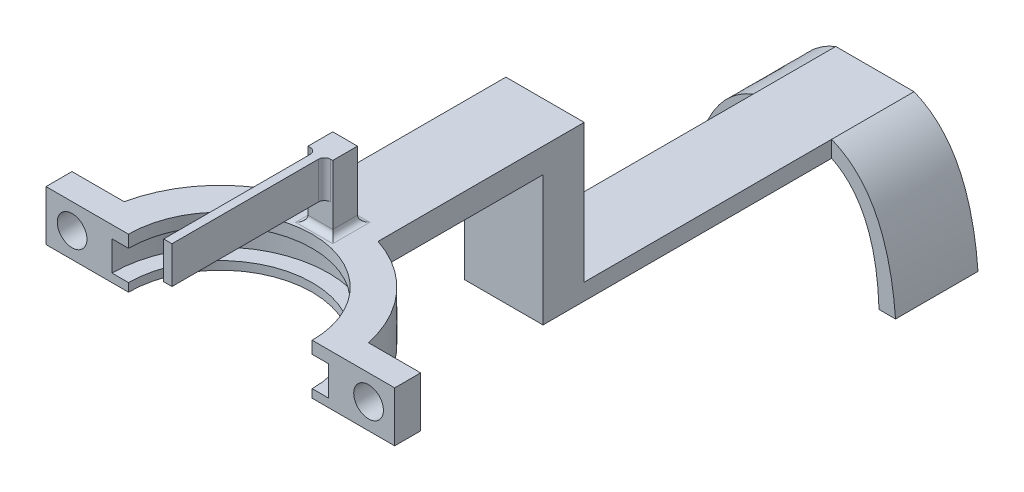
from build123d import *

# Parameters (mm, degrees)
BOSS_EXTRUDE1_DEPTH = 6.5
BOSS_EXTRUDE2_DEPTH = 3
BOSS_EXTRUDE3_DEPTH = 3
SKETCH10_W          = 9.5
SKETCH10_H          = 5
BOSS_EXTRUDE4_DEPTH = 15.78
SKETCH11_W          = 9.5
SKETCH11_H          = 2
BOSS_EXTRUDE5_DEPTH = 40
BOSS_EXTRUDE6_DEPTH = 6.09393
SKETCH14_R          = 1.8
CUT_EXTRUDE1_DEPTH  = 6.3
SKETCH15_W          = 51.153217575
SKETCH15_H          = 21.210560201
CUT_EXTRUDE3_DEPTH  = 19.78
SKETCH18_W          = 3
SKETCH18_H          = 3
BOSS_EXTRUDE7_DEPTH = 6.5
FILLET1_R           = 0.75
BOSS_EXTRUDE8_DEPTH = 1.5
FILLET2_R           = 0.75
BOSS_EXTRUDE9_DEPTH = 10


with BuildPart() as part:
    # Sketch3 → Revolve1 (revolve)
    with BuildSketch(Plane.XY):
        Polygon((-62.694264441, 11.733728816), (-64.884531744, 11.733728816), (-64.884531744, 5.639799249), (-60.884531744, 5.639799249), (-60.884531744, 6.650679103), (-62.884531744, 6.650679103), (-62.884531744, 10.250679103), (-60.884531744, 10.250679103), (-60.884531744, 11.733728816), align=None)
    revolve(axis=Axis((-49.744264441, 0, 0), (0, 1, 0)))

    # Sketch7 → Boss-Extrude1 (add)
    with BuildSketch(Plane(origin=(0, 11.733728816, 0), x_dir=(1, 0, 0), z_dir=(0, 1, 0))):
        with BuildLine():
            Line((-50.244264441, 15.132008921), (-50.244264441, 13.130751112))
            ThreePointArc((-50.244264441, 13.130751112), (-49.744264441, 13.140267302), (-49.244264441, 13.130751112))
            Line((-49.244264441, 13.130751112), (-49.244264441, 15.132008921))
            ThreePointArc((-49.244264441, 15.132008921), (-49.744264441, 15.140267302), (-50.244264441, 15.132008921))
        make_face()
    extrude(amount=BOSS_EXTRUDE1_DEPTH)

    # Sketch8 → Boss-Extrude2 (add)
    with BuildSketch(Plane(origin=(0, 18.233728816, 0), x_dir=(1, 0, 0), z_dir=(0, 1, 0))):
        with BuildLine():
            Line((-50.244264441, 15.132008921), (-50.244264441, 13.130751112))
            Line((-50.244264441, 13.130751112), (-50.244264441, -6.369248888))
            Line((-50.244264441, -6.369248888), (-49.244264441, -6.369248888))
            Line((-49.244264441, -6.369248888), (-49.244264441, 13.130751112))
            Line((-49.244264441, 13.130751112), (-49.244264441, 15.132008921))
            ThreePointArc((-49.244264441, 15.132008921), (-49.744264441, 15.140267302), (-50.244264441, 15.132008921))
        make_face()
    extrude(amount=-BOSS_EXTRUDE2_DEPTH)

    # Sketch9 → Boss-Extrude3 (add)
    with BuildSketch(Plane(origin=(0, 11.733728816, 0), x_dir=(1, 0, 0), z_dir=(0, 1, 0))):
        with BuildLine():
            Line((-54.494264441, 14.375854548), (-54.494264441, 39.375854548))
            Line((-54.494264441, 39.375854548), (-44.994264441, 39.375854548))
            Line((-44.994264441, 39.375854548), (-44.994264441, 14.375854548))
            ThreePointArc((-44.994264441, 14.375854548), (-47.092177082, 14.906177465), (-49.244264441, 15.132008921))
            ThreePointArc((-49.244264441, 15.132008921), (-49.744264441, 15.140267302), (-50.244264441, 15.132008921))
            ThreePointArc((-50.244264441, 15.132008921), (-52.3963518, 14.906177465), (-54.494264441, 14.375854548))
        make_face()
    extrude(amount=-BOSS_EXTRUDE3_DEPTH)

    # Sketch10 → Boss-Extrude4 (add)
    with BuildSketch(Plane.XZ.offset(-8.733728816)):
        with Locations((-49.744264441, -36.875854548)):
            Rectangle(SKETCH10_W, SKETCH10_H)
    extrude(amount=BOSS_EXTRUDE4_DEPTH)

    # Sketch11 → Boss-Extrude5 (add)
    with BuildSketch(Plane(origin=(0, 0, -39.375854548), x_dir=(-1, 0, 0), z_dir=(0, 0, -1))):
        with Locations((49.744264441, -6.046271184)):
            Rectangle(SKETCH11_W, SKETCH11_H)
    extrude(amount=BOSS_EXTRUDE5_DEPTH)

    # Sketch13 → Boss-Extrude6 (add)
    with BuildSketch(Plane(origin=(0, 11.733728816, 0), x_dir=(1, 0, 0), z_dir=(0, 1, 0))):
        with BuildLine():
            Line((-28.603997139, 3.15), (-34.935307895, 3.15))
            ThreePointArc((-34.935307895, 3.15), (-34.603997139, 0), (-34.935307895, -3.15))
            Line((-34.935307895, -3.15), (-28.603997139, -3.15))
            Line((-28.603997139, -3.15), (-28.603997139, 3.15))
        make_face()
        with BuildLine():
            Line((-70.884531744, 3.15), (-70.884531744, -3.15))
            Line((-70.884531744, -3.15), (-64.553220987, -3.15))
            ThreePointArc((-64.553220987, -3.15), (-64.884531744, 0), (-64.553220987, 3.15))
            Line((-64.553220987, 3.15), (-70.884531744, 3.15))
        make_face()
    extrude(amount=-BOSS_EXTRUDE6_DEPTH)

    # Sketch14 → Cut-Extrude1 (cut)
    with BuildSketch(Plane.XY.offset(3.15)):
        with Locations((-31.769652517, 8.686764033)):
            Circle(SKETCH14_R)
        with Locations((-67.718876365, 8.686764033)):
            Circle(SKETCH14_R)
    extrude(amount=-CUT_EXTRUDE1_DEPTH, mode=Mode.SUBTRACT)

    # Sketch15 → Cut-Extrude3 (cut, through all)
    with BuildSketch(Plane(origin=(0, 11.733728816, 0), x_dir=(1, 0, 0), z_dir=(0, 1, 0))):
        with Locations((-49.018725857, -10.6052801)):
            Rectangle(SKETCH15_W, SKETCH15_H)
    extrude(amount=-CUT_EXTRUDE3_DEPTH, mode=Mode.SUBTRACT)

    # Sketch18 → Boss-Extrude7 (add)
    with BuildSketch(Plane(origin=(0, 11.733728816, 0), x_dir=(1, 0, 0), z_dir=(0, 1, 0))):
        with Locations((-49.744264441, 13.632008921)):
            Rectangle(SKETCH18_W, SKETCH18_H)
    extrude(amount=BOSS_EXTRUDE7_DEPTH)

    # Fillet1
    fillet1_edges = [part.edges().sort_by_distance(p)[0] for p in [
        (-50.744264441, 11.733728816, -15.132008921),
        (-48.744264441, 11.733728816, -15.132008921),
        (-49.744264441, 11.733728816, -12.132008921),
        (-48.244264441, 11.733728816, -13.632008921),
        (-51.244264441, 11.733728816, -13.632008921),
        (-49.744264441, 11.733728816, -15.140267302),
    ]]
    fillet(fillet1_edges, radius=FILLET1_R)

    # Sketch19 → Boss-Extrude8 (add)
    with BuildSketch(Plane(origin=(0, 18.233728816, 0), x_dir=(1, 0, 0), z_dir=(0, 1, 0))):
        with BuildLine():
            Line((-50.244264441, 15.132008921), (-51.244264441, 15.132008921))
            Line((-51.244264441, 15.132008921), (-51.244264441, 12.132008921))
            Line((-51.244264441, 12.132008921), (-50.244264441, 12.132008921))
            Line((-50.244264441, 12.132008921), (-50.244264441, -6.369248888))
            Line((-50.244264441, -6.369248888), (-49.244264441, -6.369248888))
            Line((-49.244264441, -6.369248888), (-49.244264441, 12.132008921))
            Line((-49.244264441, 12.132008921), (-48.244264441, 12.132008921))
            Line((-48.244264441, 12.132008921), (-48.244264441, 15.132008921))
            Line((-48.244264441, 15.132008921), (-49.244264441, 15.132008921))
            ThreePointArc((-49.244264441, 15.132008921), (-49.744264441, 15.140267302), (-50.244264441, 15.132008921))
        make_face()
    extrude(amount=BOSS_EXTRUDE8_DEPTH)

    # Fillet2
    fillet2_edges = [part.edges().sort_by_distance(p)[0] for p in [
        (-50.244264441, 17.483728816, -12.132008921),
        (-49.244264441, 17.483728816, -12.132008921),
    ]]
    fillet(fillet2_edges, radius=FILLET2_R)

    # Sketch20 → Boss-Extrude9 (add)
    with BuildSketch(Plane(origin=(0, 0, -79.375854548), x_dir=(-1, 0, 0), z_dir=(0, 0, -1))):
        with BuildLine():
            Line((37.244264441, -20.046271184), (39.244264441, -20.046271184))
            add(Edge.make_bspline(
                [(39.244264441, -20.046271184), (39.582311707, -9.650122804), (44.994264441, -7.046271184)],
                knots=[0, 0, 0, 0.599407443, 0.599407443, 0.599407443], degree=2))
            Line((44.994264441, -7.046271184), (54.494264441, -7.046271184))
            add(Edge.make_bspline(
                [(54.494264441, -7.046271184), (59.906217176, -9.650122804), (60.244264441, -20.046271184)],
                knots=[0.400592557, 0.400592557, 0.400592557, 1, 1, 1], degree=2))
            Line((60.244264441, -20.046271184), (62.244264441, -20.046271184))
            add(Edge.make_bspline(
                [(62.244264441, -20.046271184), (61.29176104, -7.746792571), (54.494264441, -5.046271184)],
                knots=[0, 0, 0, 0.639930482, 0.639930482, 0.639930482], degree=2))
            Line((54.494264441, -5.046271184), (44.994264441, -5.046271184))
            add(Edge.make_bspline(
                [(37.244264441, -20.046271184), (38.196767843, -7.746792571), (44.994264441, -5.046271184)],
                knots=[0, 0, 0, 0.639930482, 0.639930482, 0.639930482], degree=2))
        make_face()
    extrude(amount=-BOSS_EXTRUDE9_DEPTH)


solid = part.part
